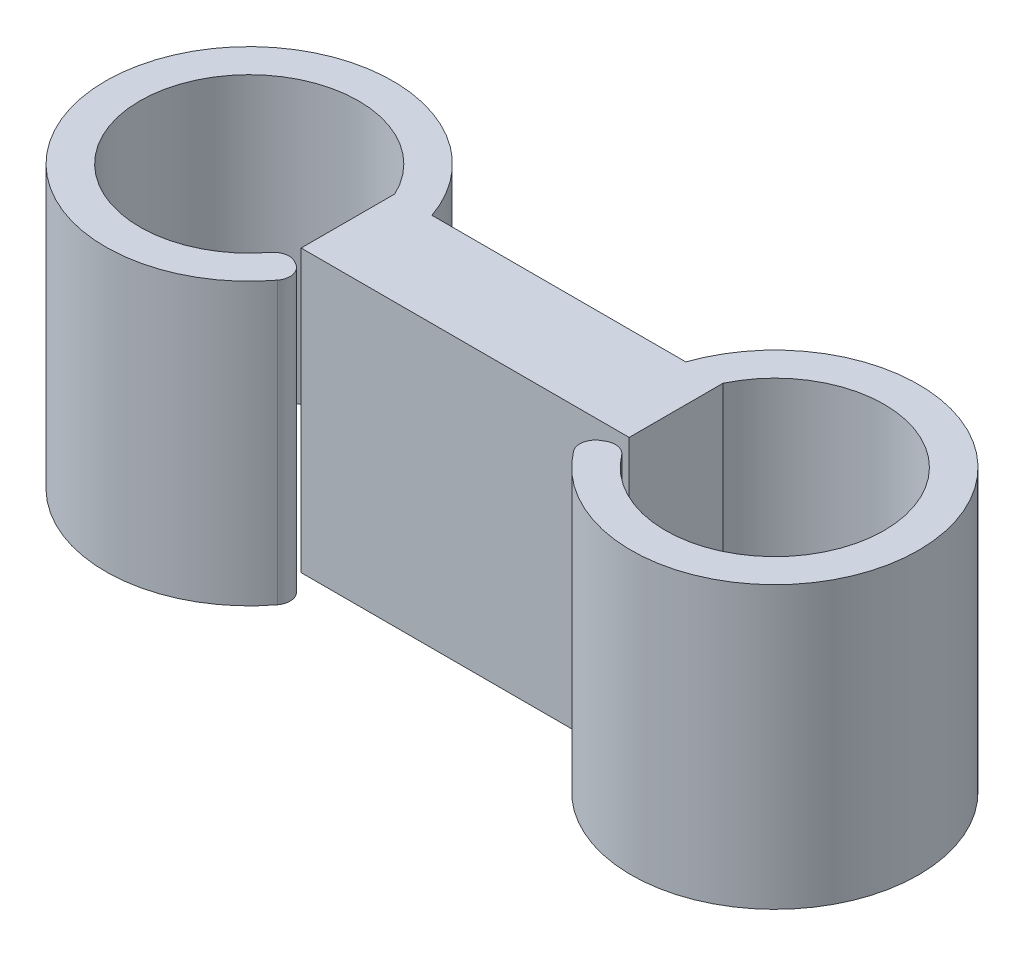
from build123d import *

# Parameters (mm, degrees)
SKETCH1_W           = 21
SKETCH1_H           = 6
BOSS_EXTRUDE1_DEPTH = 18
BOSS_EXTRUDE2_DEPTH = 18
FILLET1_R           = 1


with BuildPart() as part:
    # Sketch1 → Boss-Extrude1 (new body)
    with BuildSketch(Plane(origin=(0, 0, 0), x_dir=(1, 0, 0), z_dir=(0, 1, 0))):
        Rectangle(SKETCH1_W, SKETCH1_H)
    extrude(amount=BOSS_EXTRUDE1_DEPTH)

    # Sketch2 → Boss-Extrude2 (add)
    with BuildSketch(Plane(origin=(0, 18, 0), x_dir=(1, 0, 0), z_dir=(0, 1, 0))):
        with BuildLine():
            Line((-10.5, 3), (-8.127429358, 3))
            ThreePointArc((-8.127429358, 3), (-25.982441938, 0.879268272), (-8.857121606, -4.6))
            Line((-8.857121606, -4.6), (-10.762377494, -3.5))
            ThreePointArc((-10.762377494, -3.5), (-23.818859397, 0.282330458), (-10.5, 3))
        make_face()
        with BuildLine():
            Line((10.762377494, -3.5), (8.857121606, -4.6))
            ThreePointArc((8.857121606, -4.6), (25.982441938, 0.879268272), (8.127429358, 3))
            Line((8.127429358, 3), (10.5, 3))
            ThreePointArc((10.5, 3), (23.818859397, 0.282330458), (10.762377494, -3.5))
        make_face()
    extrude(amount=-BOSS_EXTRUDE2_DEPTH)

    # Fillet1
    fillet1_edges = [part.edges().sort_by_distance(p)[0] for p in [
        (-10.762377494, 9, 3.5),
        (-8.857121606, 9, 4.6),
        (8.857121606, 9, 4.6),
        (10.762377494, 9, 3.5),
    ]]
    fillet(fillet1_edges, radius=FILLET1_R)


solid = part.part
